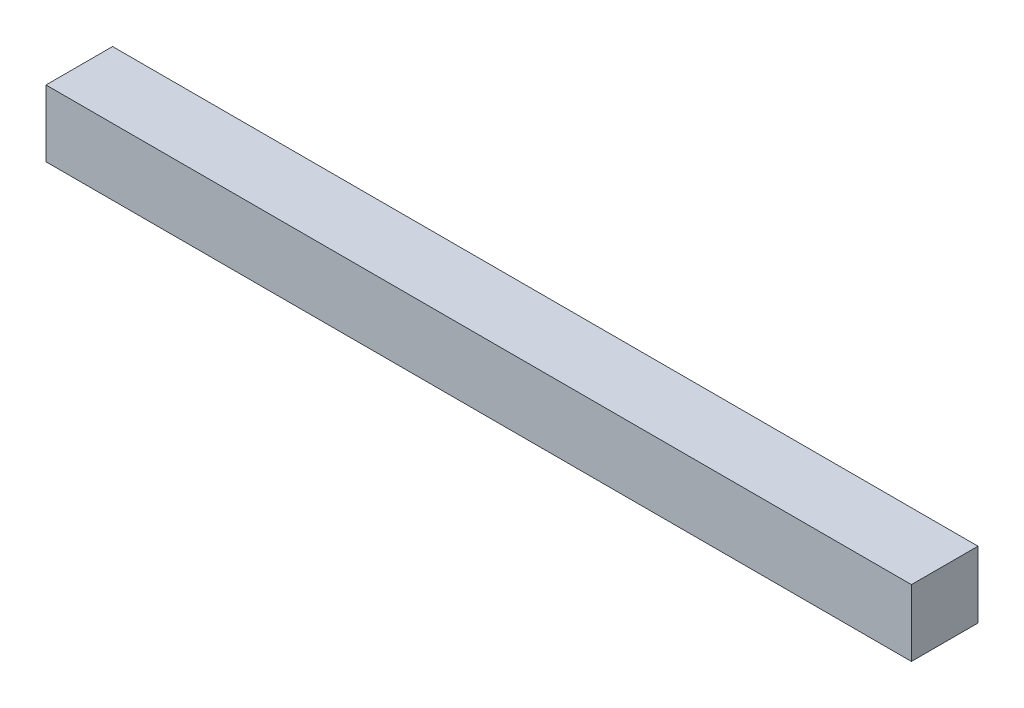
from build123d import *

# Parameters (mm, degrees)
SKETCH1_W           = 330.2
SKETCH1_H           = 25.4
BOSS_EXTRUDE1_DEPTH = 25.4


with BuildPart() as part:
    # Sketch1 → Boss-Extrude1 (new body)
    with BuildSketch(Plane(origin=(0, 0, 0), x_dir=(1, 0, 0), z_dir=(0, 1, 0))):
        Rectangle(SKETCH1_W, SKETCH1_H)
    extrude(amount=BOSS_EXTRUDE1_DEPTH)


solid = part.part
